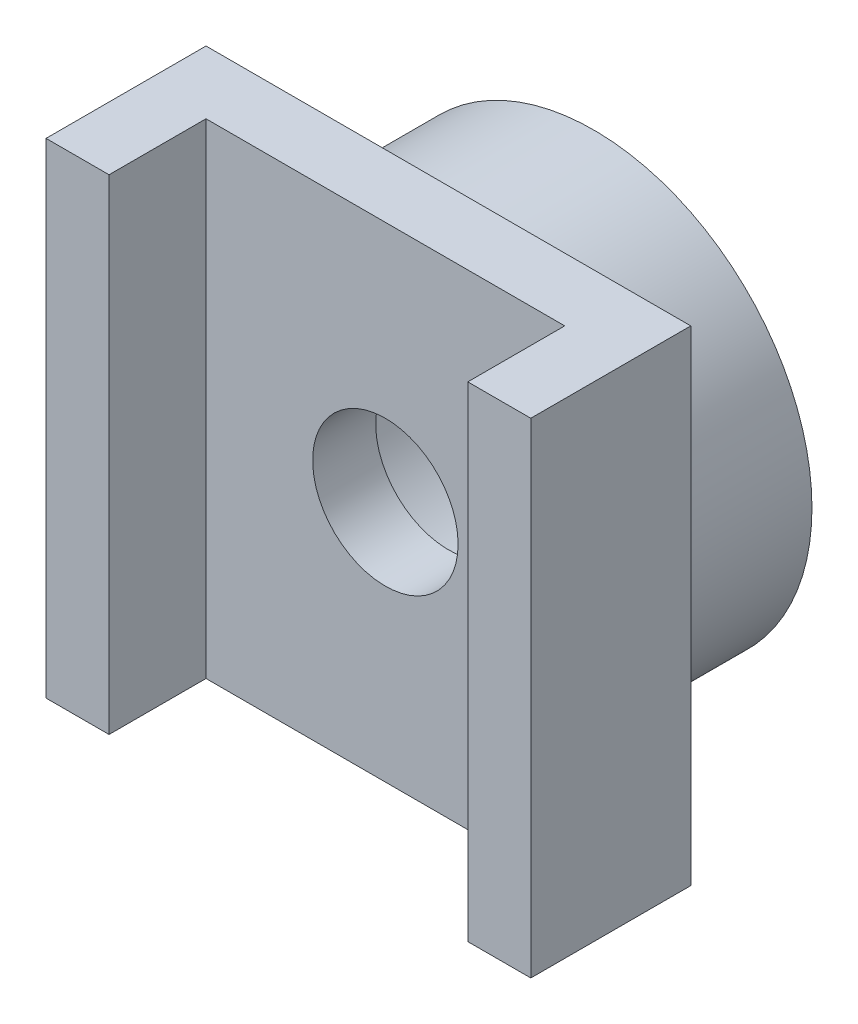
from build123d import *

# Parameters (mm, degrees)
SKETCH1_R           = 4.5
SKETCH1_R_2         = 2.8
BOSS_EXTRUDE1_DEPTH = 3
SKETCH2_W           = 10
SKETCH2_H           = 10
SKETCH2_R           = 1.5
BOSS_EXTRUDE2_DEPTH = 1.3
SKETCH3_W           = 1.3
SKETCH3_H           = 10
BOSS_EXTRUDE3_DEPTH = 2


with BuildPart() as part:
    # Sketch1 → Boss-Extrude1 (new body)
    with BuildSketch(Plane.XY):
        Circle(SKETCH1_R)
        Circle(SKETCH1_R_2, mode=Mode.SUBTRACT)
    extrude(amount=BOSS_EXTRUDE1_DEPTH)

    # Sketch2 → Boss-Extrude2 (add)
    with BuildSketch(Plane.XY.offset(3)):
        Rectangle(SKETCH2_W, SKETCH2_H)
        Circle(SKETCH2_R, mode=Mode.SUBTRACT)
    extrude(amount=BOSS_EXTRUDE2_DEPTH)

    # Sketch3 → Boss-Extrude3 (add)
    with BuildSketch(Plane.XY.offset(4.3)):
        with Locations((-4.35, 0)):
            Rectangle(SKETCH3_W, SKETCH3_H)
        with Locations((4.35, 0)):
            Rectangle(SKETCH3_W, SKETCH3_H)
    extrude(amount=BOSS_EXTRUDE3_DEPTH)


solid = part.part
